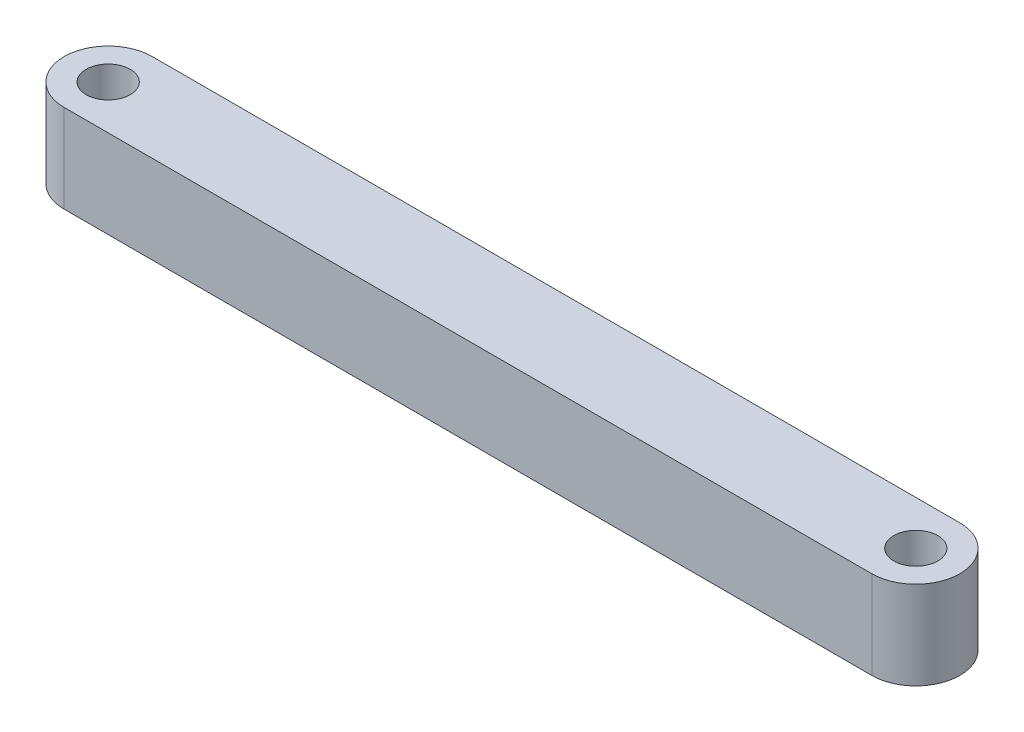
from build123d import *

# Parameters (mm, degrees)
SKETCH1_R           = 1.5
BOSS_EXTRUDE1_DEPTH = 6


with BuildPart() as part:
    # Sketch1 → Boss-Extrude1 (new body)
    with BuildSketch(Plane(origin=(0, 0, 0), x_dir=(1, 0, 0), z_dir=(0, 1, 0))):
        with BuildLine():
            Line((0, 0), (-55, 0))
            ThreePointArc((-55, 0), (-58, 3), (-55, 6))
            Line((-55, 6), (0, 6))
            ThreePointArc((0, 6), (3, 3), (0, 0))
        make_face()
        with Locations((-55, 3)):
            Circle(SKETCH1_R, mode=Mode.SUBTRACT)
        with Locations((0, 3)):
            Circle(SKETCH1_R, mode=Mode.SUBTRACT)
    extrude(amount=BOSS_EXTRUDE1_DEPTH)


solid = part.part
